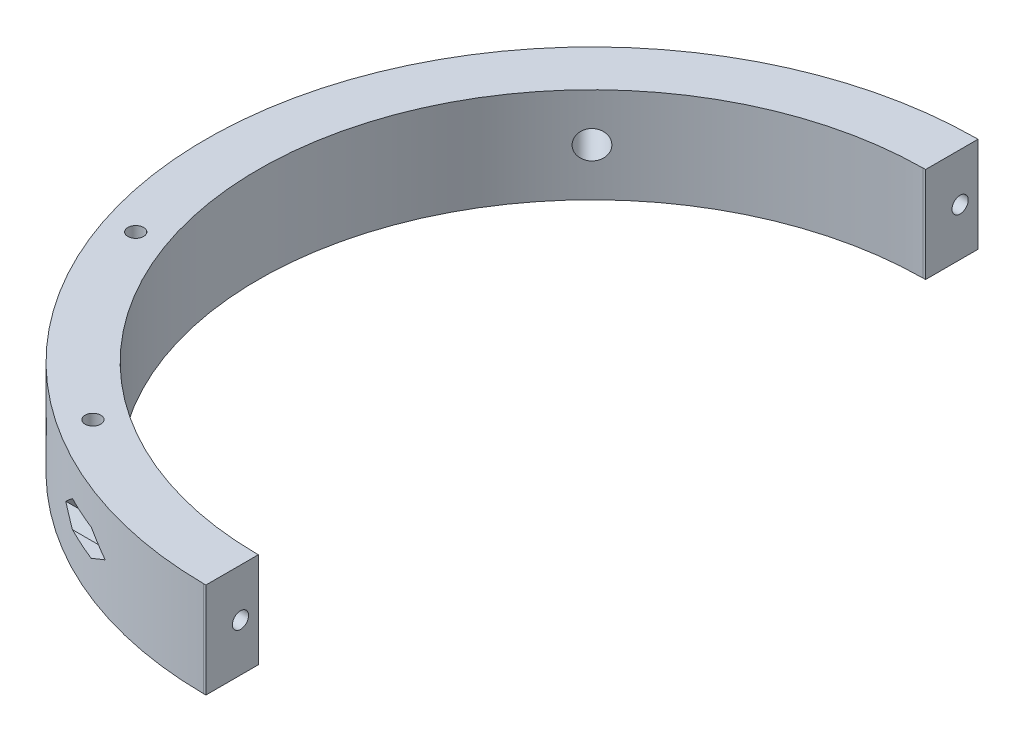
from build123d import *

# Parameters (mm, degrees)
BOSS_EXTRUDE1_DEPTH   = 10
SKETCH2_W             = 162
SKETCH2_H             = 20
CUT_EXTRUDE1_DEPTH    = 0.5
CUT_EXTRUDE2_DEPTH    = 67.5
F_6_0MM_DOWEL_HOLE2_D = 5.9
F_6_0MM_DOWEL_HOLE4_D = 5.9
SKETCH30_R            = 1.65
CUT_EXTRUDE7_DEPTH    = 20
SKETCH31_W            = 11.000242512
SKETCH31_H            = 20
BOSS_EXTRUDE2_DEPTH   = 0.5
SKETCH5_R             = 1.7
CUT_EXTRUDE3_DEPTH    = 115


with BuildPart() as part:
    # Sketch1 → Boss-Extrude1 (new body, symmetric)
    with BuildSketch(Plane(origin=(0, 0, 0), x_dir=(1, 0, 0), z_dir=(0, 1, 0))):
        with BuildLine():
            Line((0, 70), (0, 81))
            ThreePointArc((0, 81), (-81, 0), (0, -81))
            Line((0, -81), (0, -70))
            ThreePointArc((0, -70), (-70, 0), (0, 70))
        make_face()
    extrude(amount=BOSS_EXTRUDE1_DEPTH, both=True)

    # Sketch2 → Cut-Extrude1 (cut)
    with BuildSketch(Plane(origin=(0, 0, 0), x_dir=(0, 0, -1), z_dir=(1, 0, 0))):
        Rectangle(SKETCH2_W, SKETCH2_H)
    extrude(amount=-CUT_EXTRUDE1_DEPTH, mode=Mode.SUBTRACT)

    # Sketch4 → Cut-Extrude2 (cut)
    with BuildSketch(Plane(origin=(-75, 0, 0), x_dir=(0, 0, -1), z_dir=(1, 0, 0))):
        Polygon((-72.117199752, 2.825), (-75.379228773, 2.825), (-77.010243284, 0), (-75.379228773, -2.825), (-72.117199752, -2.825), (-70.486185242, 0), align=None)
        Polygon((80.510485796, 0), (78.879471286, 2.825), (75.617442265, 2.825), (73.986427755, 0), (75.617442265, -2.825), (78.879471286, -2.825), align=None)
    extrude(amount=CUT_EXTRUDE2_DEPTH, mode=Mode.SUBTRACT)

    # Ø6.0mm Dowel Hole2 (through all)
    with Locations(Plane(origin=(0, 0, 0), x_dir=(-0.707106781, 0, -0.707106781), z_dir=(0.707106781, 0, -0.707106781))):
        with Locations((0, 0)):
            Hole(F_6_0MM_DOWEL_HOLE2_D / 2)

    # Ø6.0mm Dowel Hole4 (through all)
    with Locations(Plane(origin=(0, 0, 0), x_dir=(0.707106781, 0, -0.707106781), z_dir=(0.707106781, 0, 0.707106781))):
        with Locations((0, 0)):
            Hole(F_6_0MM_DOWEL_HOLE4_D / 2)

    # Sketch30 → Cut-Extrude7 (cut, symmetric)
    with BuildSketch(Plane.XZ.offset(10)):
        with Locations((-41.894091711, 62.810310298)):
            Circle(SKETCH30_R)
        with Locations((-71.513705419, 24.208261757)):
            Circle(SKETCH30_R)
    extrude(amount=CUT_EXTRUDE7_DEPTH, both=True, mode=Mode.SUBTRACT)

    # Sketch31 → Boss-Extrude2 (add)
    with BuildSketch(Plane(origin=(-0.5, 0, 0), x_dir=(0, 0, -1), z_dir=(1, 0, 0))):
        with Locations((-75.498335519, 0)):
            Rectangle(SKETCH31_W, SKETCH31_H)
        with Locations((75.498335519, 0)):
            Rectangle(SKETCH31_W, SKETCH31_H)
    extrude(amount=BOSS_EXTRUDE2_DEPTH)

    # Sketch5 → Cut-Extrude3 (cut, symmetric)
    with BuildSketch(Plane(origin=(-75, 0, 0), x_dir=(0, 0, -1), z_dir=(1, 0, 0))):
        with Locations((77.248456775, 0)):
            Circle(SKETCH5_R)
        with Locations((-73.748214263, 0)):
            Circle(SKETCH5_R)
    extrude(amount=CUT_EXTRUDE3_DEPTH, both=True, mode=Mode.SUBTRACT)


solid = part.part
